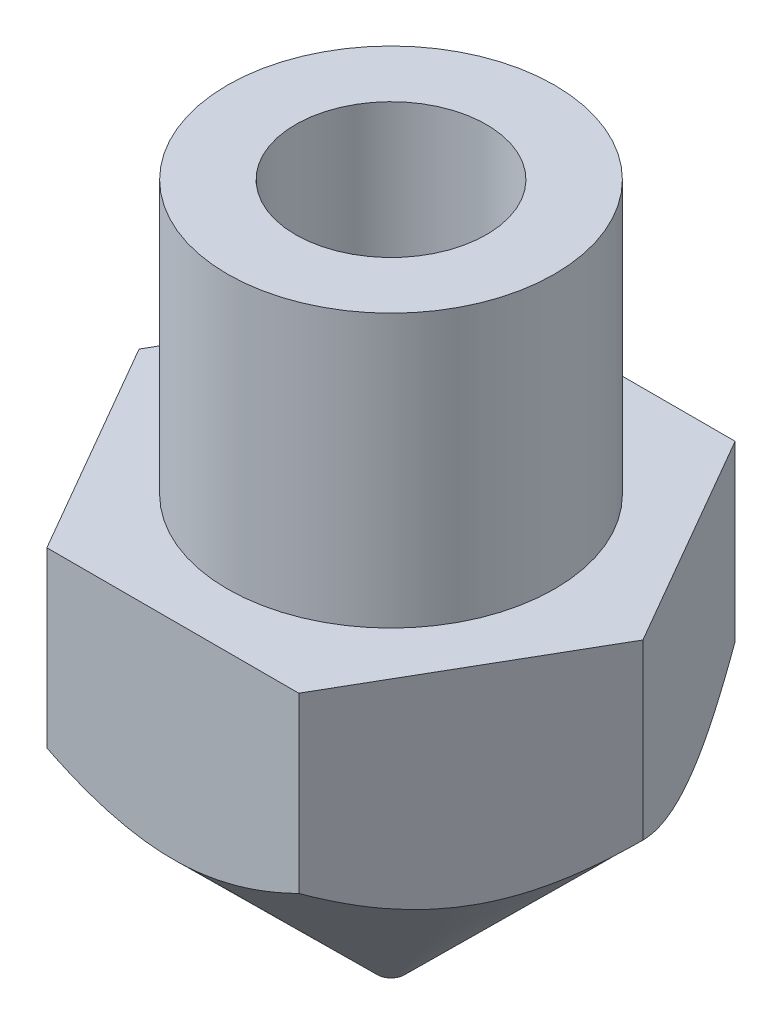
from build123d import *

# Parameters (mm, degrees)
BOSS_EXTRUDE1_DEPTH = 3
SKETCH3_R           = 5.46173703
CUT_EXTRUDE1_DEPTH  = 10
CUT_EXTRUDE2_REACH  = 11.674
SKETCH4_R           = 1.75
SKETCH5_R           = 3
SKETCH5_R_2         = 1.75
BOSS_EXTRUDE2_DEPTH = 5


with BuildPart() as part:
    # Sketch1 → Revolve1 (revolve)
    with BuildSketch(Plane.XY):
        Polygon((-0.2, 0), (-0.25, 0), (-4.8, 4.5), (-1.75, 4.5), (-1.75, 2.684678752), align=None)
    revolve(axis=Axis((0, 0, 0), (0, 1, 0)))

    # Sketch2 → Boss-Extrude1 (add)
    with BuildSketch(Plane(origin=(0, 4.5, 0), x_dir=(1, 0, 0), z_dir=(0, 1, 0))):
        Polygon((2.309401077, -4), (4.618802154, 0), (2.309401077, 4), (-2.309401077, 4), (-4.618802154, 0), (-2.309401077, -4), align=None)
    extrude(amount=BOSS_EXTRUDE1_DEPTH)

    # Sketch3 → Cut-Extrude1 (cut)
    with BuildSketch(Plane(origin=(0, 7.5, 0), x_dir=(1, 0, 0), z_dir=(0, 1, 0))):
        Circle(SKETCH3_R)
        Polygon((-2.309401077, -4), (2.309401077, -4), (4.618802154, 0), (2.309401077, 4), (-2.309401077, 4), (-4.618802154, 0), align=None, mode=Mode.SUBTRACT)
    extrude(amount=-CUT_EXTRUDE1_DEPTH, mode=Mode.SUBTRACT)

    # Sketch4 → Cut-Extrude2 (cut, up to next)
    with BuildSketch(Plane(origin=(0, 7.5, 0), x_dir=(1, 0, 0), z_dir=(0, 1, 0)), mode=Mode.PRIVATE) as cut_extrude2_sk1:
        Circle(SKETCH4_R)
    cut_extrude2_tool1 = extrude(cut_extrude2_sk1.sketch, amount=-CUT_EXTRUDE2_REACH, mode=Mode.PRIVATE) & part.part
    add(cut_extrude2_tool1.solids().sort_by_distance((0, 7.5, 0))[0], mode=Mode.SUBTRACT)

    # Sketch5 → Boss-Extrude2 (add)
    with BuildSketch(Plane(origin=(0, 7.5, 0), x_dir=(1, 0, 0), z_dir=(0, 1, 0))):
        Circle(SKETCH5_R)
        Circle(SKETCH5_R_2, mode=Mode.SUBTRACT)
    extrude(amount=BOSS_EXTRUDE2_DEPTH)


solid = part.part
